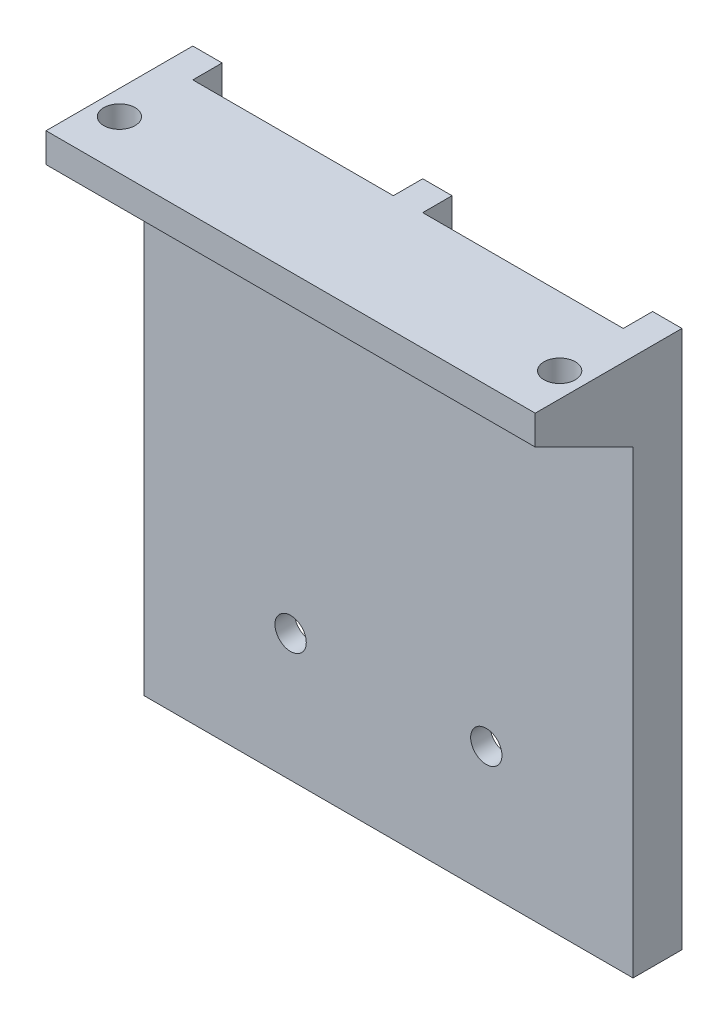
from build123d import *

# Parameters (mm, degrees)
SKETCH_1_R          = 1.6
EXTRUDE_2_DEPTH     = 2
SKETCH_2_W          = 50
SKETCH_2_H          = 3
EXTRUDE_3_DEPTH     = 10
SKETCH_3_R          = 1.45
CUT_EXTRUDE_1_DEPTH = 3
EXTRUDE_4_DEPTH     = 50
SKETCH_8_R          = 1.6
CUT_EXTRUDE_4_DEPTH = 4
SKETCH_7_R          = 2.3
CUT_EXTRUDE_6_DEPTH = 20
SKETCH_10_W         = 3
SKETCH_10_H         = 55
EXTRUDE_5_DEPTH     = 3


with BuildPart() as part:
    # 草图1 → 凸台-拉伸2 (new body)
    with BuildSketch(Plane.XY):
        Polygon((25, -4.951489209), (25, -59.951489209), (-25, -59.951489209), (-25, -4.951489209), (0, -4.951489209), align=None)
        with Locations((10, -46.951489209)):
            Circle(SKETCH_1_R, mode=Mode.SUBTRACT)
        with Locations((-10, -46.951489209)):
            Circle(SKETCH_1_R, mode=Mode.SUBTRACT)
    extrude(amount=-EXTRUDE_2_DEPTH)

    # 草图2 → 凸台-拉伸3 (add)
    with BuildSketch(Plane.XY):
        with Locations((0, -6.451489209)):
            Rectangle(SKETCH_2_W, SKETCH_2_H)
    extrude(amount=EXTRUDE_3_DEPTH)

    # 草图3 → 切除-拉伸1 (cut)
    with BuildSketch(Plane(origin=(0, -7.951489209, 0), x_dir=(-1, 0, 0), z_dir=(0, -1, 0))):
        with Locations((22.5, -5)):
            Circle(SKETCH_3_R)
        with Locations((-22.5, -5)):
            Circle(SKETCH_3_R)
    extrude(amount=-CUT_EXTRUDE_1_DEPTH, mode=Mode.SUBTRACT)

    # 草图5 → 凸台-拉伸4 (add)
    with BuildSketch(Plane(origin=(25, -7.951489209, 0), x_dir=(0, 0, -1), z_dir=(1, 0, 0))):
        Polygon((-10, 0), (0, 0), (0, -5), align=None)
    extrude(amount=-EXTRUDE_4_DEPTH)

    # 草图8 → 切除-拉伸4 (cut, through all)
    with BuildSketch(Plane(origin=(0, -7.951489209, 0), x_dir=(-1, 0, 0), z_dir=(0, -1, 0))):
        with Locations((-22.5, -5)):
            Circle(SKETCH_8_R)
        with Locations((22.5, -5)):
            Circle(SKETCH_8_R)
    extrude(amount=-CUT_EXTRUDE_4_DEPTH, mode=Mode.SUBTRACT)

    # 草图7 → 切除-拉伸6 (cut)
    with BuildSketch(Plane(origin=(0, -7.951489209, 0), x_dir=(-1, 0, 0), z_dir=(0, -1, 0))):
        with Locations((-22.5, -5)):
            Circle(SKETCH_7_R)
        with Locations((22.5, -5)):
            Circle(SKETCH_7_R)
    extrude(amount=CUT_EXTRUDE_6_DEPTH, mode=Mode.SUBTRACT)

    # 草图10 → 凸台-拉伸5 (add)
    with BuildSketch(Plane(origin=(0, 0, -2), x_dir=(-1, 0, 0), z_dir=(0, 0, -1))):
        Polygon((-1.5, -59.951489209), (0, -59.951489209), (1.5, -59.951489209), (1.5, -4.951489209), (0, -4.951489209), (-1.5, -4.951489209), align=None)
        with Locations((23.5, -32.451489209)):
            Rectangle(SKETCH_10_W, SKETCH_10_H)
        with Locations((-23.5, -32.451489209)):
            Rectangle(SKETCH_10_W, SKETCH_10_H)
    extrude(amount=EXTRUDE_5_DEPTH)


solid = part.part
